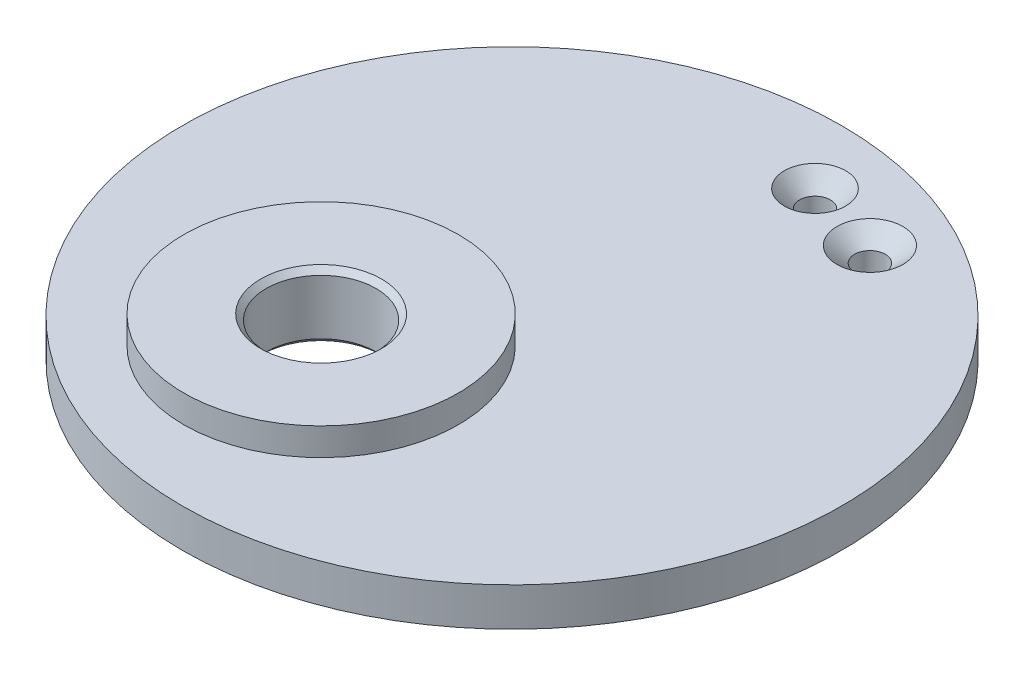
from build123d import *

# Parameters (mm, degrees)
SKETCH1_R               = 38.1
BOSS_EXTRUDE1_DEPTH     = 4.445
SKETCH2_R               = 14.4145
SKETCH2_R_2             = 1.778
CUT_EXTRUDE1_DEPTH      = 1
CUT_EXTRUDE1_DEPTH_BACK = 5.445
CHAMFER1_SIZE           = 2.032
CHAMFER1_SIZE2          = 1.766390651
CHAMFER1_PART_2_SIZE    = 2.032
CHAMFER1_PART_2_SIZE2   = 1.766390651
SKETCH10_R              = 15.875
SKETCH10_R_2            = 6.35
BOSS_EXTRUDE5_DEPTH     = 7.62
CHAMFER2_SIZE           = 0.635


with BuildPart() as part:
    # Sketch1 → Boss-Extrude1 (new body)
    with BuildSketch(Plane(origin=(0, 0, 0), x_dir=(1, 0, 0), z_dir=(0, 1, 0))):
        Circle(SKETCH1_R)
    extrude(amount=BOSS_EXTRUDE1_DEPTH)

    # Sketch2 → Cut-Extrude1 (cut, two sides)
    with BuildSketch(Plane(origin=(0, 4.445, 0), x_dir=(1, 0, 0), z_dir=(0, 1, 0))) as cut_extrude1_sk:
        with Locations((-8.06, -14.01)):
            Circle(SKETCH2_R)
        with Locations((4.759999878, 30.270007278)):
            Circle(SKETCH2_R_2)
        with Locations((13.649999878, 27.730007278)):
            Circle(SKETCH2_R_2)
    extrude(amount=CUT_EXTRUDE1_DEPTH, mode=Mode.SUBTRACT)
    extrude(cut_extrude1_sk.sketch, amount=-CUT_EXTRUDE1_DEPTH_BACK, mode=Mode.SUBTRACT)

    # Chamfer1
    chamfer1_edges = [part.edges().sort_by_distance(p)[0] for p in [
        (2.981999878, 4.445, -30.270007278),
    ]]
    chamfer1_side = [part.faces().sort_by_distance(p)[0] for p in [
        (2.981999878, 2.2225, -30.270007278),
    ]]
    chamfer(chamfer1_edges, length=CHAMFER1_SIZE, length2=CHAMFER1_SIZE2, reference=chamfer1_side[0])

    # Chamfer1 part 2
    chamfer1_part_2_edges = [part.edges().sort_by_distance(p)[0] for p in [
        (11.871999878, 4.445, -27.730007278),
    ]]
    chamfer1_part_2_side = [part.faces().sort_by_distance(p)[0] for p in [
        (1.306244319, 4.445, -2.20411426),
    ]]
    chamfer(chamfer1_part_2_edges, length=CHAMFER1_PART_2_SIZE, length2=CHAMFER1_PART_2_SIZE2, reference=chamfer1_part_2_side[0])

    # Sketch10 → Boss-Extrude5 (add)
    with BuildSketch(Plane.XZ):
        with Locations((-8.06, 14.01)):
            Circle(SKETCH10_R)
        with Locations((-8.06, 14.01)):
            Circle(SKETCH10_R_2, mode=Mode.SUBTRACT)
    extrude(amount=-BOSS_EXTRUDE5_DEPTH)

    # Chamfer2
    chamfer2_edges = [part.edges().sort_by_distance(p)[0] for p in [
        (-14.41, 7.62, 14.01),
        (-14.41, 0, 14.01),
    ]]
    chamfer(chamfer2_edges, length=CHAMFER2_SIZE)


solid = part.part
